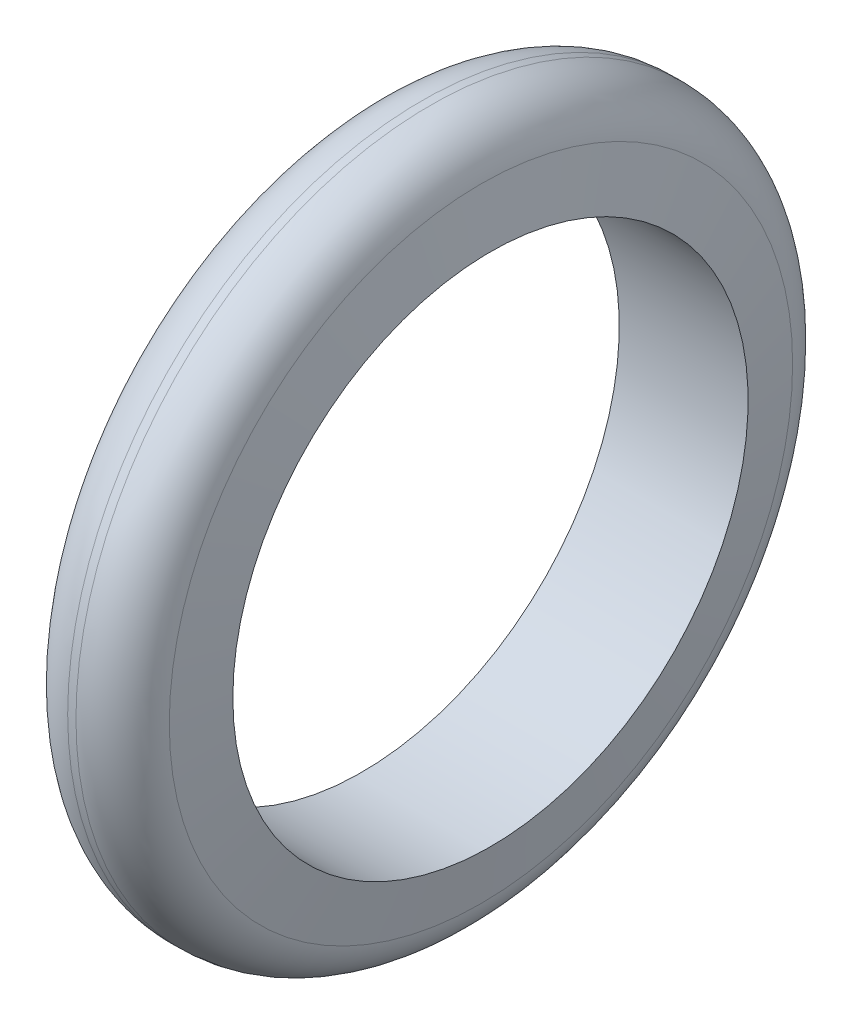
from build123d import *

# Parameters (mm, degrees)
FILLET1_R = 8


with BuildPart() as part:
    # Sketch1 → Revolve1 (revolve)
    with BuildSketch(Plane(origin=(0, 0, 0), x_dir=(1, 0, 0), z_dir=(0, 1, 0))):
        Polygon((-10, 40), (10, 40), (7.355095289, 55), (-7.355095289, 55), align=None)
    revolve(axis=Axis((0, 0, 0), (1, 0, 0)))

    # Fillet1
    fillet1_edges = [part.edges().sort_by_distance(p)[0] for p in [
        (-7.355095289, 0, 55),
        (7.355095289, 0, 55),
    ]]
    fillet(fillet1_edges, radius=FILLET1_R)


solid = part.part
